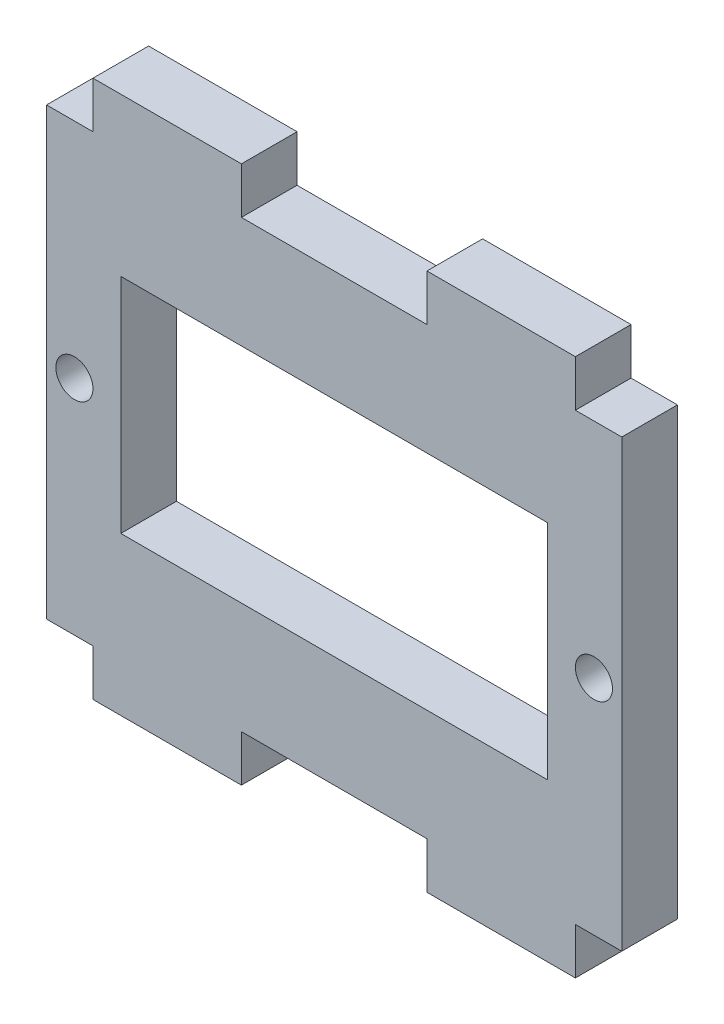
from build123d import *

# Parameters (mm, degrees)
SKETCH1_R           = 1
SKETCH1_W           = 23
SKETCH1_H           = 12
BOSS_EXTRUDE1_DEPTH = 1.5


with BuildPart() as part:
    # Sketch1 → Boss-Extrude1 (new body, symmetric)
    with BuildSketch(Plane.XY):
        Polygon((-13, 12), (-15.5, 12), (-15.5, -12), (-13, -12), (-13, -14.5), (-5, -14.5), (-5, -12), (5, -12), (5, -14.5), (13, -14.5), (13, -12), (15.5, -12), (15.5, 12), (13, 12), (13, 14.5), (5, 14.5), (5, 12), (-5, 12), (-5, 14.5), (-13, 14.5), align=None)
        with Locations((-14, 0)):
            Circle(SKETCH1_R, mode=Mode.SUBTRACT)
        Rectangle(SKETCH1_W, SKETCH1_H, mode=Mode.SUBTRACT)
        with Locations((14, 0)):
            Circle(SKETCH1_R, mode=Mode.SUBTRACT)
    extrude(amount=BOSS_EXTRUDE1_DEPTH, both=True)


solid = part.part
